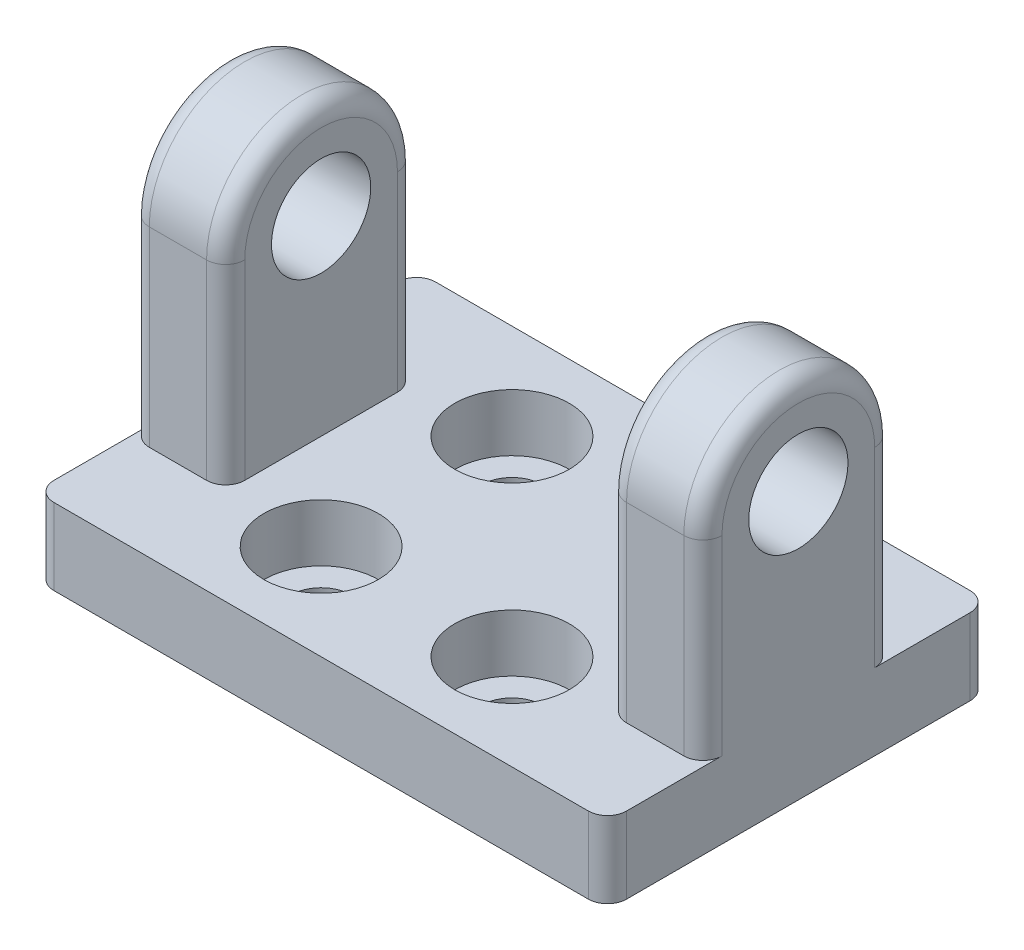
from build123d import *

# Parameters (mm, degrees)
ESQUISSE2_R             = 2.6
BOSS_EXTRU_1_DEPTH      = 15
ESQUISSE4_W             = 30
ESQUISSE4_H             = 20
BOSS_EXTRU_2_DEPTH      = 4
ENL_V_MAT_EXTRU_1_REACH = 6
ESQUISSE5_R             = 1.6
ESQUISSE6_W             = 20
ESQUISSE6_H             = 21.543710407
ENL_V_MAT_EXTRU_2_DEPTH = 16
ESQUISSE7_R             = 3
ENL_V_MAT_EXTRU_3_DEPTH = 3
CONG_1_R                = 1


with BuildPart() as part:
    # Esquisse2 → Boss.-Extru.1 (new body, symmetric)
    with BuildSketch(Plane(origin=(0, 0, 0), x_dir=(0, 0, -1), z_dir=(1, 0, 0))):
        with BuildLine():
            Line((5, 0), (5, -10))
            Line((5, -10), (-5, -10))
            Line((-5, -10), (-5, 0))
            ThreePointArc((-5, 0), (0, 5), (5, 0))
        make_face()
        Circle(ESQUISSE2_R, mode=Mode.SUBTRACT)
    extrude(amount=BOSS_EXTRU_1_DEPTH, both=True)

    # Esquisse4 → Boss.-Extru.2 (add)
    with BuildSketch(Plane.XZ.offset(10)):
        Rectangle(ESQUISSE4_W, ESQUISSE4_H)
    extrude(amount=BOSS_EXTRU_2_DEPTH)

    # Esquisse5 → Enlèv. mat.-Extru.1 (cut, up to next)
    with BuildSketch(Plane(origin=(0, -10, 0), x_dir=(1, 0, 0), z_dir=(0, 1, 0)), mode=Mode.PRIVATE) as enl_v_mat_extru_1_sk1:
        with Locations(Location((5, -5, 0), (0, 0, 270))):  # turned: the seam where the file's is
            Circle(ESQUISSE5_R)
    enl_v_mat_extru_1_tool1 = extrude(enl_v_mat_extru_1_sk1.sketch, amount=-ENL_V_MAT_EXTRU_1_REACH, mode=Mode.PRIVATE) & part.part
    add(enl_v_mat_extru_1_tool1.solids().sort_by_distance((5, -10, 5))[0], mode=Mode.SUBTRACT)
    # Esquisse5 → Enlèv. mat.-Extru.1 (cut, up to next)
    with BuildSketch(Plane(origin=(0, -10, 0), x_dir=(1, 0, 0), z_dir=(0, 1, 0)), mode=Mode.PRIVATE) as enl_v_mat_extru_1_sk2:
        with Locations(Location((5, 5, 0), (0, 0, 270))):  # turned: the seam where the file's is
            Circle(ESQUISSE5_R)
    enl_v_mat_extru_1_tool2 = extrude(enl_v_mat_extru_1_sk2.sketch, amount=-ENL_V_MAT_EXTRU_1_REACH, mode=Mode.PRIVATE) & part.part
    add(enl_v_mat_extru_1_tool2.solids().sort_by_distance((5, -10, -5))[0], mode=Mode.SUBTRACT)
    # Esquisse5 → Enlèv. mat.-Extru.1 (cut, up to next)
    with BuildSketch(Plane(origin=(0, -10, 0), x_dir=(1, 0, 0), z_dir=(0, 1, 0)), mode=Mode.PRIVATE) as enl_v_mat_extru_1_sk3:
        with Locations(Location((-5, 5, 0), (0, 0, 270))):  # turned: the seam where the file's is
            Circle(ESQUISSE5_R)
    enl_v_mat_extru_1_tool3 = extrude(enl_v_mat_extru_1_sk3.sketch, amount=-ENL_V_MAT_EXTRU_1_REACH, mode=Mode.PRIVATE) & part.part
    add(enl_v_mat_extru_1_tool3.solids().sort_by_distance((-5, -10, -5))[0], mode=Mode.SUBTRACT)
    # Esquisse5 → Enlèv. mat.-Extru.1 (cut, up to next)
    with BuildSketch(Plane(origin=(0, -10, 0), x_dir=(1, 0, 0), z_dir=(0, 1, 0)), mode=Mode.PRIVATE) as enl_v_mat_extru_1_sk4:
        with Locations(Location((-5, -5, 0), (0, 0, 270))):  # turned: the seam where the file's is
            Circle(ESQUISSE5_R)
    enl_v_mat_extru_1_tool4 = extrude(enl_v_mat_extru_1_sk4.sketch, amount=-ENL_V_MAT_EXTRU_1_REACH, mode=Mode.PRIVATE) & part.part
    add(enl_v_mat_extru_1_tool4.solids().sort_by_distance((-5, -10, 5))[0], mode=Mode.SUBTRACT)

    # Esquisse6 → Enlèv. mat.-Extru.2 (cut, through all)
    with BuildSketch(Plane.XY.offset(5)):
        with Locations((0, 0.771855204)):
            Rectangle(ESQUISSE6_W, ESQUISSE6_H)
    extrude(amount=-ENL_V_MAT_EXTRU_2_DEPTH, mode=Mode.SUBTRACT)

    # Esquisse7 → Enlèv. mat.-Extru.3 (cut)
    with BuildSketch(Plane(origin=(0, -10, 0), x_dir=(1, 0, 0), z_dir=(0, 1, 0))):
        with Locations(Location((-5, 5, 0), (0, 0, 270))):  # turned: the seam where the file's is
            Circle(ESQUISSE7_R)
        with Locations(Location((5, 5, 0), (0, 0, 270))):  # turned: the seam where the file's is
            Circle(ESQUISSE7_R)
        with Locations(Location((5, -5, 0), (0, 0, 270))):  # turned: the seam where the file's is
            Circle(ESQUISSE7_R)
        with Locations(Location((-5, -5, 0), (0, 0, 270))):  # turned: the seam where the file's is
            Circle(ESQUISSE7_R)
    extrude(amount=-ENL_V_MAT_EXTRU_3_DEPTH, mode=Mode.SUBTRACT)

    # Congé1
    cong_1_edges = [part.edges().sort_by_distance(p)[0] for p in [
        (15, -5, -5),
        (-15, -12, 10),
        (-15, -12, -10),
        (15, -12, -10),
        (15, -12, 10),
        (15, 5, 0),
        (-15, -5, -5),
        (-15, -5, 5),
        (-15, 5, 0),
        (-10, 5, 0),
        (-10, -5, -5),
        (10, -5, -5),
        (10, 5, 0),
        (10, -5, 5),
        (-10, -5, 5),
        (15, -5, 5),
    ]]
    fillet(cong_1_edges, radius=CONG_1_R)


solid = part.part
